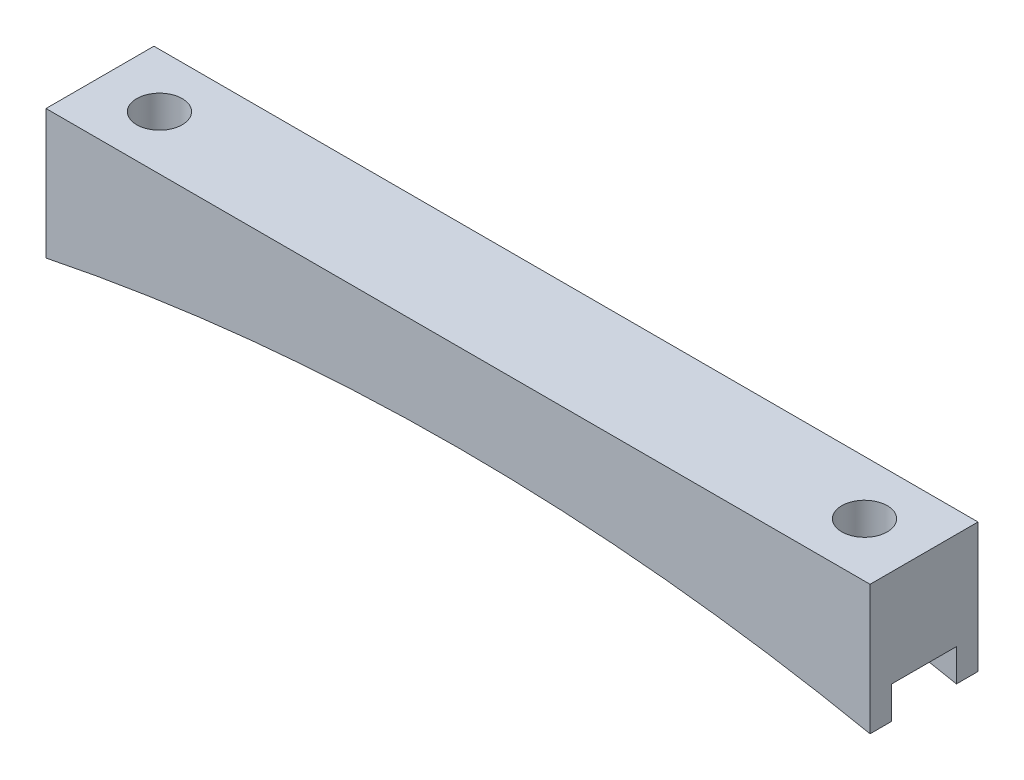
from build123d import *

# Parameters (mm, degrees)
BOSS_EXTRUDE1_DEPTH = 12.7
SKETCH2_R           = 2.675
CUT_EXTRUDE1_DEPTH  = 16.24
SKETCH3_W           = 7.62
SKETCH3_H           = 3.81
CUT_EXTRUDE2_DEPTH  = 97.9700001


with BuildPart() as part:
    # Sketch1 → Boss-Extrude1 (new body)
    with BuildSketch(Plane.XY):
        with BuildLine():
            Line((-48.485, 0), (48.485, 0))
            Line((48.485, 0), (48.485, -15.24))
            ThreePointArc((48.485, -15.24), (0, -10.318710494), (-48.485, -15.24))
            Line((-48.485, -15.24), (-48.485, 0))
        make_face()
    extrude(amount=BOSS_EXTRUDE1_DEPTH)

    # Sketch2 → Cut-Extrude1 (cut, through all)
    with BuildSketch(Plane(origin=(0, 0, 0), x_dir=(1, 0, 0), z_dir=(0, 1, 0))):
        with Locations((-41.485, -6.35)):
            Circle(SKETCH2_R)
        with Locations((41.485, -6.35)):
            Circle(SKETCH2_R)
    extrude(amount=-CUT_EXTRUDE1_DEPTH, mode=Mode.SUBTRACT)

    # Sketch3 → Cut-Extrude2 (cut, through all)
    with BuildSketch(Plane(origin=(48.485, 0, 0), x_dir=(0, 0, -1), z_dir=(1, 0, 0))):
        with Locations((-6.35, -13.335)):
            Rectangle(SKETCH3_W, SKETCH3_H)
    extrude(amount=-CUT_EXTRUDE2_DEPTH, mode=Mode.SUBTRACT)


solid = part.part
